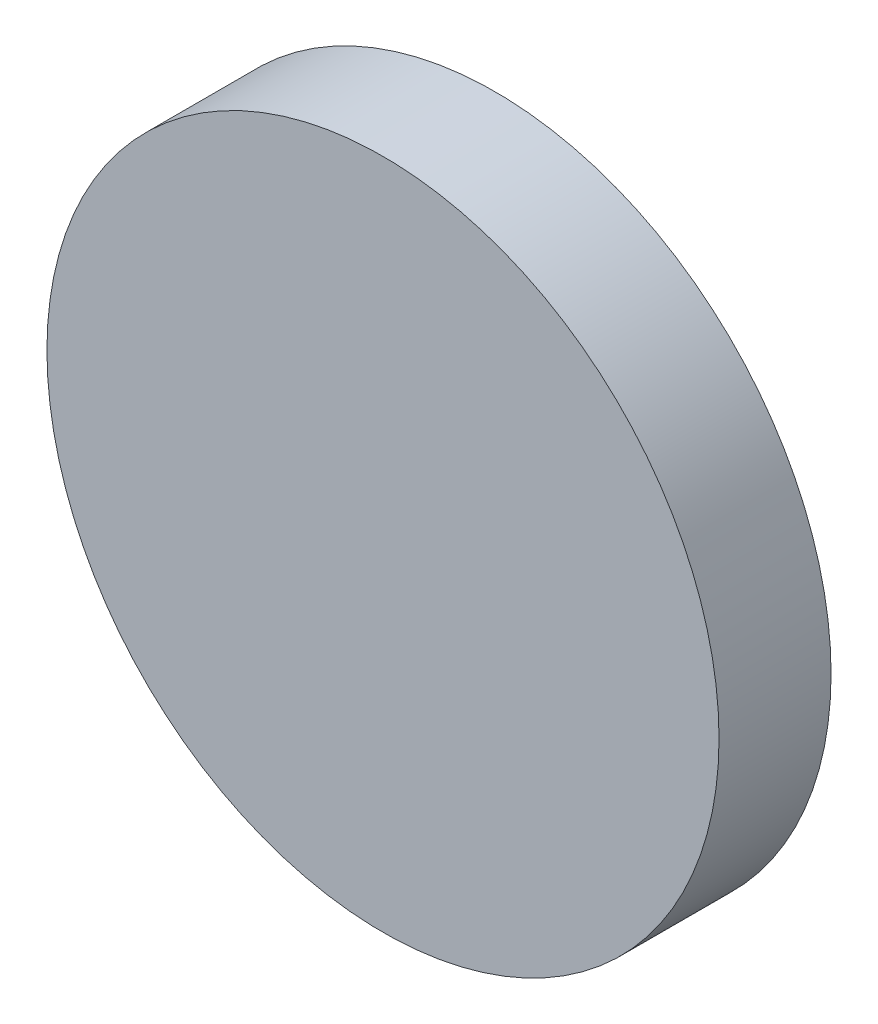
from build123d import *

# Parameters (mm, degrees)
SKETCH_1_R      = 6
EXTRUDE_1_DEPTH = 2


with BuildPart() as part:
    # 草图1 → 凸台-拉伸1 (new body)
    with BuildSketch(Plane.XY):
        Circle(SKETCH_1_R)
    extrude(amount=EXTRUDE_1_DEPTH)


solid = part.part
